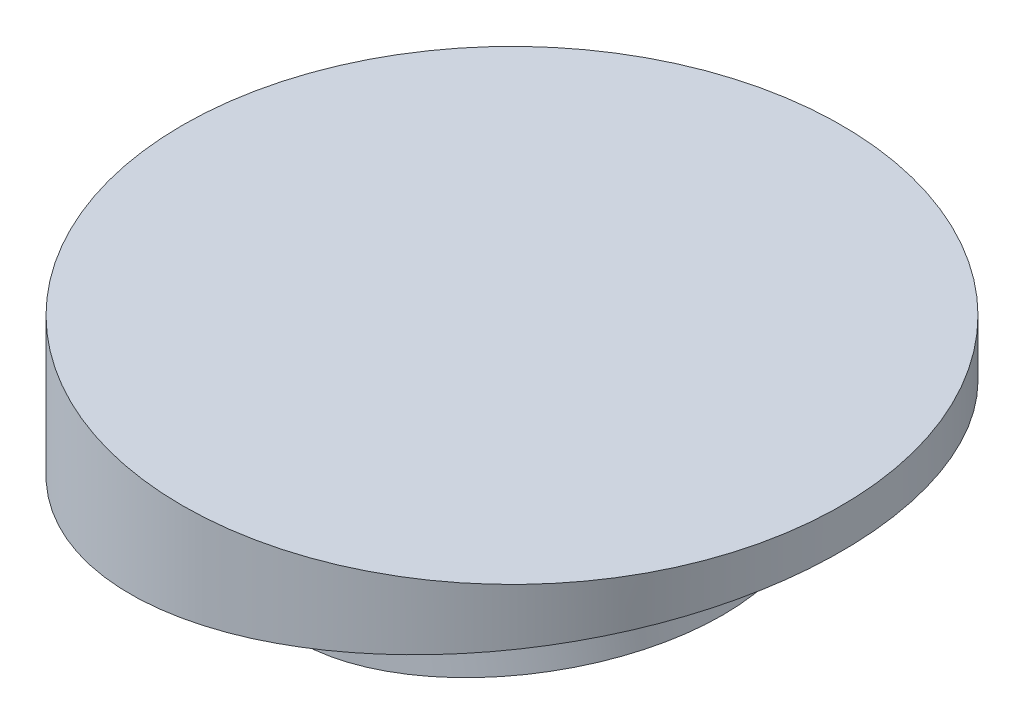
from build123d import *

# Parameters (mm, degrees)
SKETCH_5_R          = 25
EXTRUDE_4_DEPTH     = 20
CUT_EXTRUDE_2_DEPTH = 41
SKETCH_8_R          = 15
EXTRUDE_5_DEPTH     = 7


with BuildPart() as part:
    # 草图5 → 凸台-拉伸4 (new body)
    with BuildSketch(Plane(origin=(0, 0, 0), x_dir=(1, 0, 0), z_dir=(0, 1, 0))):
        Circle(SKETCH_5_R)
    extrude(amount=EXTRUDE_4_DEPTH)

    # 草图7 → 切除-拉伸2 (cut, symmetric)
    with BuildSketch(Plane.XY):
        Polygon((-25, 8.183650965), (25, 17), (25, -9.727272727), (-25, -9.727272727), align=None)
    extrude(amount=CUT_EXTRUDE_2_DEPTH, both=True, mode=Mode.SUBTRACT)

    # 草图8 → 凸台-拉伸5 (add)
    with BuildSketch(Plane(origin=(-2.153328978, 12.212135485, 0), x_dir=(0.984807753, 0.173648178, 0), z_dir=(0.173648178, -0.984807753, 0))):
        with Locations((2.186547548, 0)):
            Circle(SKETCH_8_R)
    extrude(amount=EXTRUDE_5_DEPTH)


solid = part.part
